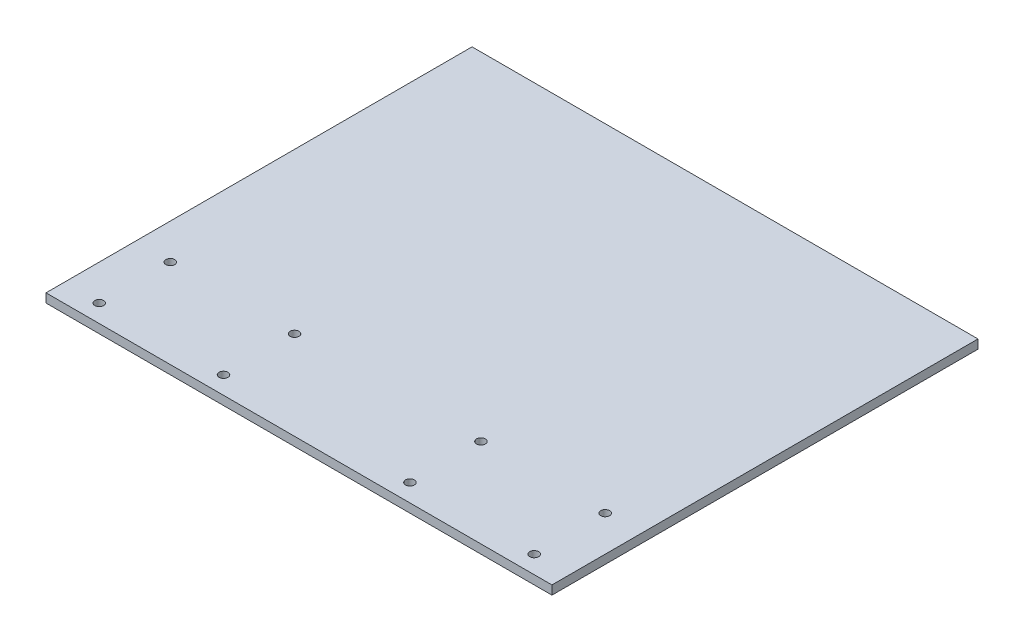
from build123d import *

# Parameters (mm, degrees)
SKETCH1_W           = 723.9
SKETCH1_H           = 609.6
BOSS_EXTRUDE1_DEPTH = 12.7
SKETCH2_R           = 6.35
CUT_EXTRUDE1_DEPTH  = 13.7


with BuildPart() as part:
    # Sketch1 → Boss-Extrude1 (new body)
    with BuildSketch(Plane(origin=(0, 0, 0), x_dir=(1, 0, 0), z_dir=(0, 1, 0))):
        with Locations((66.351143947, 304.8)):
            Rectangle(SKETCH1_W, SKETCH1_H)
    extrude(amount=BOSS_EXTRUDE1_DEPTH)

    # Sketch2 → Cut-Extrude1 (cut, through all)
    with BuildSketch(Plane(origin=(0, 12.7, 0), x_dir=(1, 0, 0), z_dir=(0, 1, 0))):
        with Locations((377.501143947, 127)):
            Circle(SKETCH2_R)
        with Locations((377.501143947, 25.4)):
            Circle(SKETCH2_R)
        with Locations((199.701143947, 127)):
            Circle(SKETCH2_R)
        with Locations((199.701143947, 25.4)):
            Circle(SKETCH2_R)
        with Locations((-244.798856053, 127)):
            Circle(SKETCH2_R)
        with Locations((-66.998856053, 127)):
            Circle(SKETCH2_R)
        with Locations((-244.798856053, 25.4)):
            Circle(SKETCH2_R)
        with Locations((-66.998856053, 25.4)):
            Circle(SKETCH2_R)
    extrude(amount=-CUT_EXTRUDE1_DEPTH, mode=Mode.SUBTRACT)


solid = part.part
